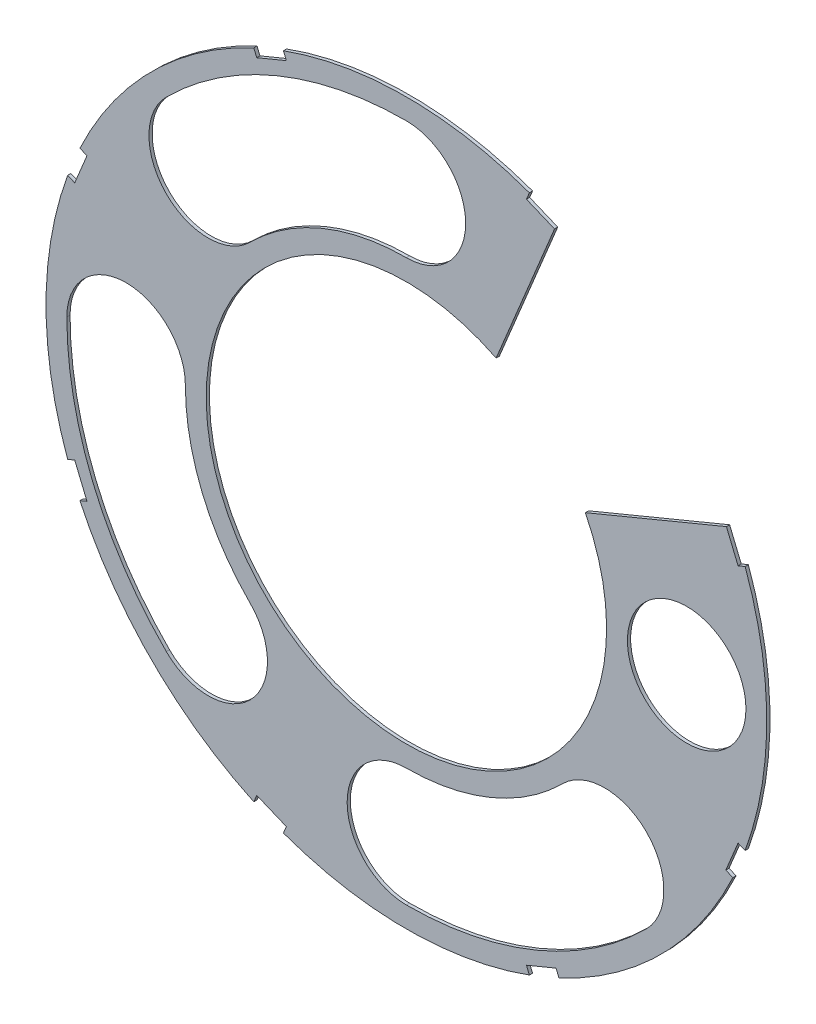
from build123d import *

# Parameters (mm, degrees)
SKETCH4_R           = 28.575
BOSS_EXTRUDE2_DEPTH = 0.254
SKETCH5_R           = 15.875
CUT_EXTRUDE5_DEPTH  = 1.254
SKETCH6_R           = 4.699
CUT_EXTRUDE6_DEPTH  = 1.254
CUT_EXTRUDE11_DEPTH = 1.254


with BuildPart() as part:
    # Sketch4 → Boss-Extrude2 (new body)
    with BuildSketch(Plane.XY):
        Circle(SKETCH4_R)
    extrude(amount=BOSS_EXTRUDE2_DEPTH)

    # Sketch5 → Cut-Extrude5 (cut, through all)
    with BuildSketch(Plane.XY.offset(0.254)):
        Circle(SKETCH5_R)
    extrude(amount=-CUT_EXTRUDE5_DEPTH, mode=Mode.SUBTRACT)

    # Sketch6 → Cut-Extrude6 (cut, through all)
    with BuildSketch(Plane.XY.offset(0.254)):
        with Locations((22.225, 0)):
            Circle(SKETCH6_R)
        with BuildLine():
            ThreePointArc((19.03814289, -19.038143063), (19.038142992, -12.392753462), (12.392753391, -12.392753504))
            ThreePointArc((12.392753391, -12.392753504), (6.706909655, -16.191912762), (-3.11e-07, -17.526))
            ThreePointArc((-3.11e-07, -17.526), (-4.699, -22.224999917), (-4.77e-07, -26.924))
            ThreePointArc((-4.77e-07, -26.924), (10.303368456, -24.874532648), (19.03814289, -19.038143063))
        make_face()
        with BuildLine():
            ThreePointArc((-19.038143063, -19.03814289), (-12.392753462, -19.038142992), (-12.392753504, -12.392753391))
            ThreePointArc((-12.392753504, -12.392753391), (-16.191912762, -6.706909655), (-17.526, 3.11e-07))
            ThreePointArc((-17.526, 3.11e-07), (-22.224999917, 4.699), (-26.924, 4.77e-07))
            ThreePointArc((-26.924, 4.77e-07), (-24.874532648, -10.303368456), (-19.038143063, -19.03814289))
        make_face()
        with BuildLine():
            ThreePointArc((-19.03814289, 19.038143063), (-19.038142992, 12.392753462), (-12.392753391, 12.392753504))
            ThreePointArc((-12.392753391, 12.392753504), (-6.706909655, 16.191912762), (3.11e-07, 17.526))
            ThreePointArc((3.11e-07, 17.526), (4.699, 22.224999917), (4.77e-07, 26.924))
            ThreePointArc((4.77e-07, 26.924), (-10.303368456, 24.874532648), (-19.03814289, 19.038143063))
        make_face()
    extrude(amount=-CUT_EXTRUDE6_DEPTH, mode=Mode.SUBTRACT)

    # Sketch8 → Cut-Extrude11 (cut, through all)
    with BuildSketch(Plane.XY.offset(0.254)):
        with BuildLine():
            Line((11.748169406, 25.375786975), (9.518848094, 26.299202097))
            Line((9.518848094, 26.299202097), (9.751046558, 26.859778778))
            ThreePointArc((9.751046558, 26.859778778), (20.205576272, 20.205576272), (26.859778778, 9.751046558))
            Line((26.859778778, 9.751046558), (26.299202097, 9.518848094))
            Line((26.299202097, 9.518848094), (25.375786975, 11.748169406))
            Line((25.375786975, 11.748169406), (14.191115224, 7.115326676))
            ThreePointArc((14.191115224, 7.115326676), (11.225320151, 11.225320151), (7.115326676, 14.191115224))
            Line((7.115326676, 14.191115224), (11.748169406, 25.375786975))
        make_face()
        Polygon((-10.004856053, 27.472529104), (-12.351510066, 26.500513186), (-11.865502107, 25.327186179), (-9.518848094, 26.299202097), align=None)
        Polygon((-26.500513186, 12.351510066), (-27.472529104, 10.004856053), (-26.299202097, 9.518848094), (-25.327186179, 11.865502107), align=None)
        Polygon((-27.472529104, -10.004856053), (-26.500513186, -12.351510066), (-25.327186179, -11.865502107), (-26.299202097, -9.518848094), align=None)
        Polygon((-12.351510066, -26.500513186), (-10.004856053, -27.472529104), (-9.518848094, -26.299202097), (-11.865502107, -25.327186179), align=None)
        Polygon((10.004856053, -27.472529104), (12.351510066, -26.500513186), (11.865502107, -25.327186179), (9.518848094, -26.299202097), align=None)
        Polygon((26.500513186, -12.351510066), (27.472529104, -10.004856053), (26.299202097, -9.518848094), (25.327186179, -11.865502107), align=None)
    extrude(amount=-CUT_EXTRUDE11_DEPTH, mode=Mode.SUBTRACT)


solid = part.part
